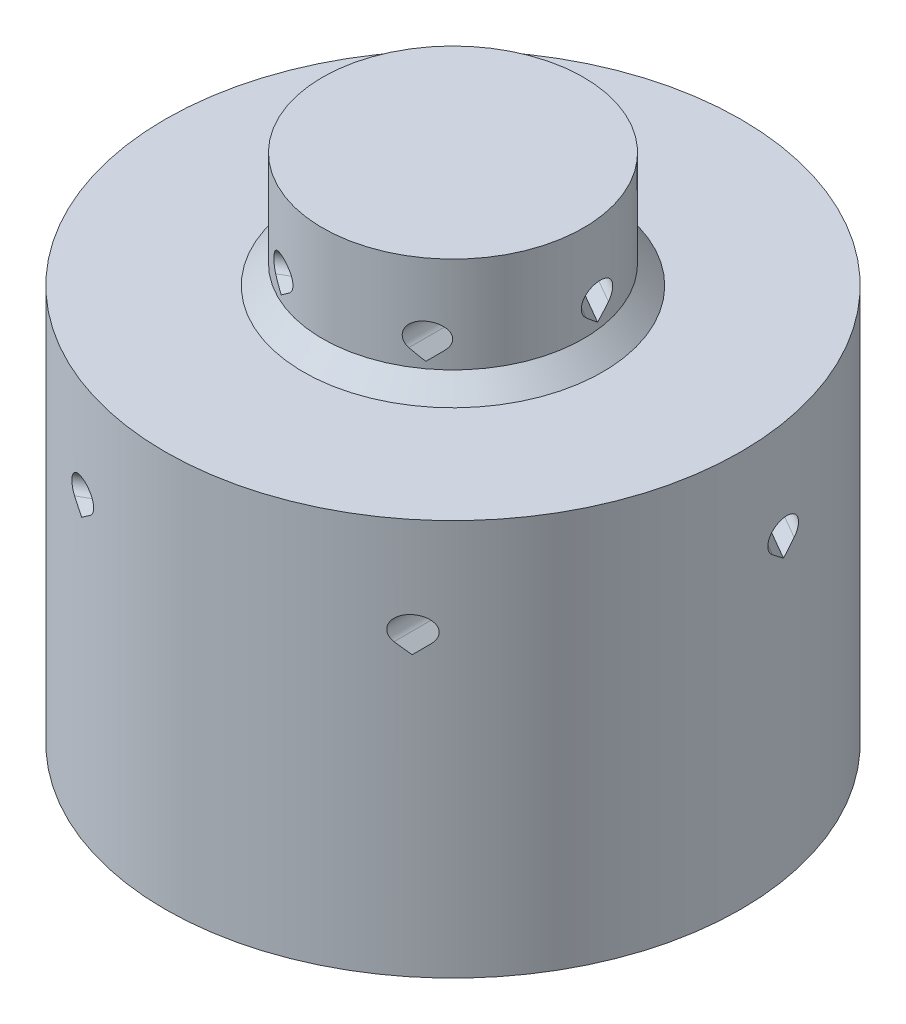
from build123d import *

# Parameters (mm, degrees)
SKETCH3_W          = 4.445
SKETCH3_H          = 1.5875
CUT_EXTRUDE1_DEPTH = 30.580471571
CIRPATTERN1_COUNT  = 6
CUT_EXTRUDE2_DEPTH = 30.580471571
CIRPATTERN2_COUNT  = 6


with BuildPart() as part:
    # Sketch1 → Revolve1 (revolve)
    with BuildSketch(Plane.XY):
        Polygon((-5.3975, 0), (-5.3975, -3.96875), (-6.19125, -4.7625), (-11.90625, -4.7625), (-11.90625, -7.1755), (-8.128, -7.1755), (-8.128, -7.9375), (-4.60375, -7.9375), (-4.60375, -13.346282015), (-3.33375, -14.616282015), (-3.33375, -16.8275), (-2.54, -16.8275), (-2.54, -14.2875), (-3.81, -13.0175), (-3.81, -1.5875), (-4.445, -1.5875), (-4.445, 0), align=None)
    revolve(axis=Axis((0, -1.5875, 0), (0, -1, 0)))

    # Sketch2 → Revolve2 (revolve)
    with BuildSketch(Plane.XY):
        Polygon((-8.128, -7.9375), (-8.128, -14.2875), (-4.445, -17.9705), (-4.445, -24.3205), (-6.35, -24.3205), (-6.35, -21.1455), (-7.3152, -21.1455), (-7.3152, -19.1643), (-10.3886, -19.1643), (-10.3886, -21.1455), (-11.90625, -21.1455), (-11.90625, -7.1755), (-8.128, -7.1755), align=None)
    revolve(axis=Axis((0, -1.5875, 0), (0, -1, 0)))

    # Sketch3 → Revolve3 (revolve)
    with BuildSketch(Plane.XY):
        with Locations((-2.2225, -0.79375)):
            Rectangle(SKETCH3_W, SKETCH3_H)
    revolve(axis=Axis((0, -1.5875, 0), (0, 1, 0)))

    # Sketch8 → Cut-Extrude1 (cut, through all)
    with BuildSketch(Plane.XY):
        with BuildLine():
            Line((-3.2146875, -3.699399011), (-3.635637006, -3.278449506))
            ThreePointArc((-3.635637006, -3.278449506), (-3.2146875, -2.2621875), (-2.793737994, -3.278449506))
            Line((-2.793737994, -3.278449506), (-3.2146875, -3.699399011))
        make_face()
    cut_extrude1 = extrude(amount=-CUT_EXTRUDE1_DEPTH, mode=Mode.SUBTRACT)

    # CirPattern1: Cut-Extrude1 ×6 about axis
    cirpattern1_axis = Axis((0, 42.935, 0), (0, -1, 0))
    for i in range(1, CIRPATTERN1_COUNT):
        add(cut_extrude1.rotate(cirpattern1_axis, i * 360 / CIRPATTERN1_COUNT), mode=Mode.SUBTRACT)

    # Sketch9 → Cut-Extrude2 (cut, through all)
    with BuildSketch(Plane.XY):
        with BuildLine():
            Line((-7.5326875, -9.604899011), (-7.953637006, -9.183949506))
            ThreePointArc((-7.953637006, -9.183949506), (-7.5326875, -8.1676875), (-7.111737994, -9.183949506))
            Line((-7.111737994, -9.183949506), (-7.5326875, -9.604899011))
        make_face()
    cut_extrude2 = extrude(amount=-CUT_EXTRUDE2_DEPTH, mode=Mode.SUBTRACT)

    # CirPattern2: Cut-Extrude2 ×6 about axis
    cirpattern2_axis = Axis((0, 42.935, 0), (0, -1, 0))
    for i in range(1, CIRPATTERN2_COUNT):
        add(cut_extrude2.rotate(cirpattern2_axis, i * 360 / CIRPATTERN2_COUNT), mode=Mode.SUBTRACT)


solid = part.part
